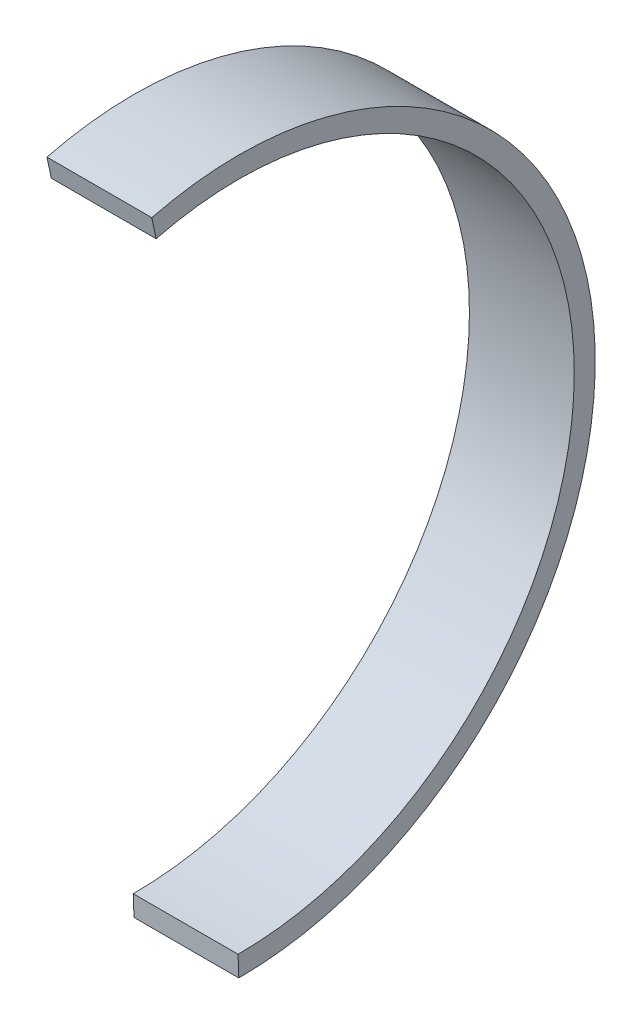
from build123d import *

# Parameters (mm, degrees)
BOSS_EXTRUDE1_DEPTH = 25


with BuildPart() as part:
    # Sketch1 → Boss-Extrude1 (new body)
    with BuildSketch(Plane(origin=(0, 0, 0), x_dir=(0, 0, -1), z_dir=(1, 0, 0))):
        with BuildLine():
            ThreePointArc((83.104024945, 0), (59.607972661, -56.633063598), (2.921427632, -79.999791614))
            Line((2.921427632, -79.999791614), (3.104024945, -85))
            ThreePointArc((3.104024945, -85), (63.208101345, -60.104076401), (88.104024945, 0))
            ThreePointArc((88.104024945, 0), (55.354704105, 67.04376576), (-17.657540402, 82.425465752))
            Line((-17.657540402, 82.425465752), (-16.609471714, 77.533077132))
            ThreePointArc((-16.609471714, 77.533077132), (52.210645004, 63.154887905), (83.104024945, 0))
        make_face()
    extrude(amount=BOSS_EXTRUDE1_DEPTH)


solid = part.part
